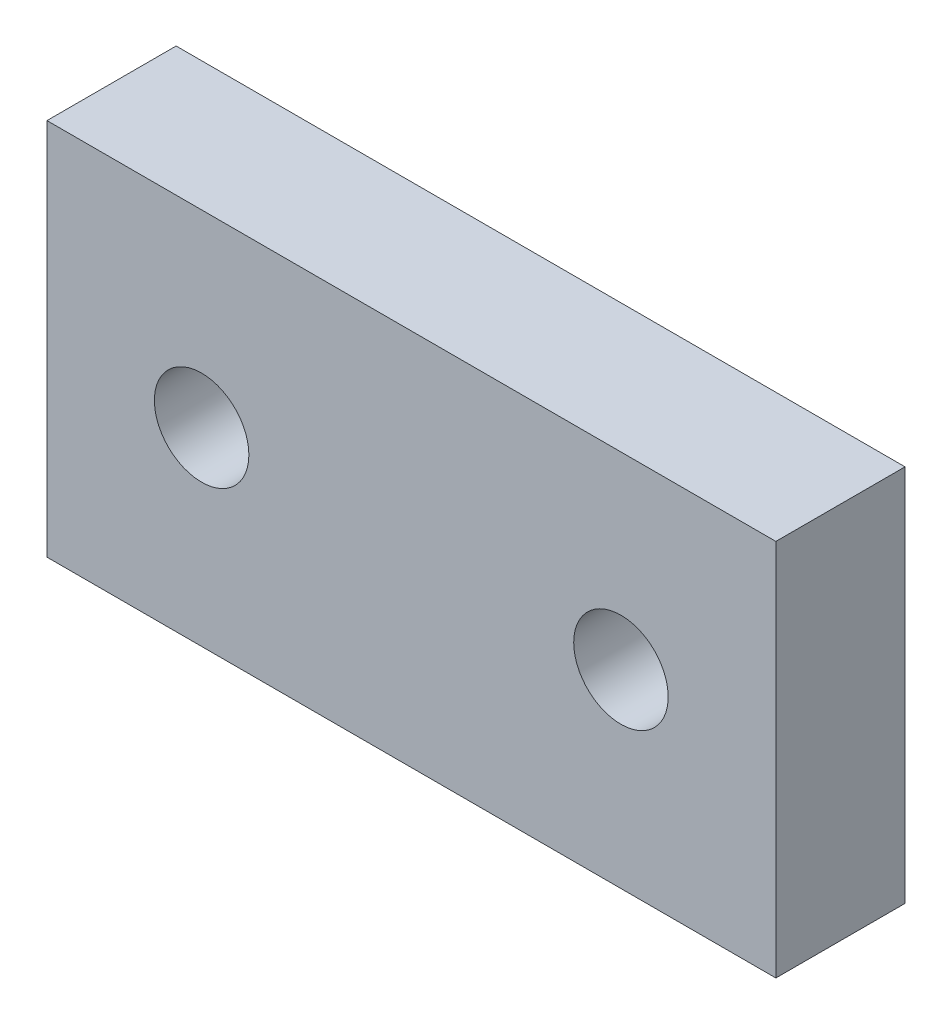
from build123d import *

# Parameters (mm, degrees)
SKETCH1_W          = 21.21128765
SKETCH1_H          = 11.00313828
BRACKETBASE_DEPTH  = 3.75882541
SKETCH2_R          = 1.375
CUT_EXTRUDE1_DEPTH = 4.75882541


with BuildPart() as part:
    # Sketch1 → bracketBase (new body)
    with BuildSketch(Plane.XY):
        with Locations((10.605643825, 5.50156914)):
            Rectangle(SKETCH1_W, SKETCH1_H)
    extrude(amount=BRACKETBASE_DEPTH)

    # Sketch2 → Cut-Extrude1 (cut, through all)
    with BuildSketch(Plane.XY.offset(3.75882541)):
        with Locations((4.50061561, 5.51479595)):
            Circle(SKETCH2_R)
        with Locations((16.70317329, 5.51479595)):
            Circle(SKETCH2_R)
    extrude(amount=-CUT_EXTRUDE1_DEPTH, mode=Mode.SUBTRACT)


solid = part.part
